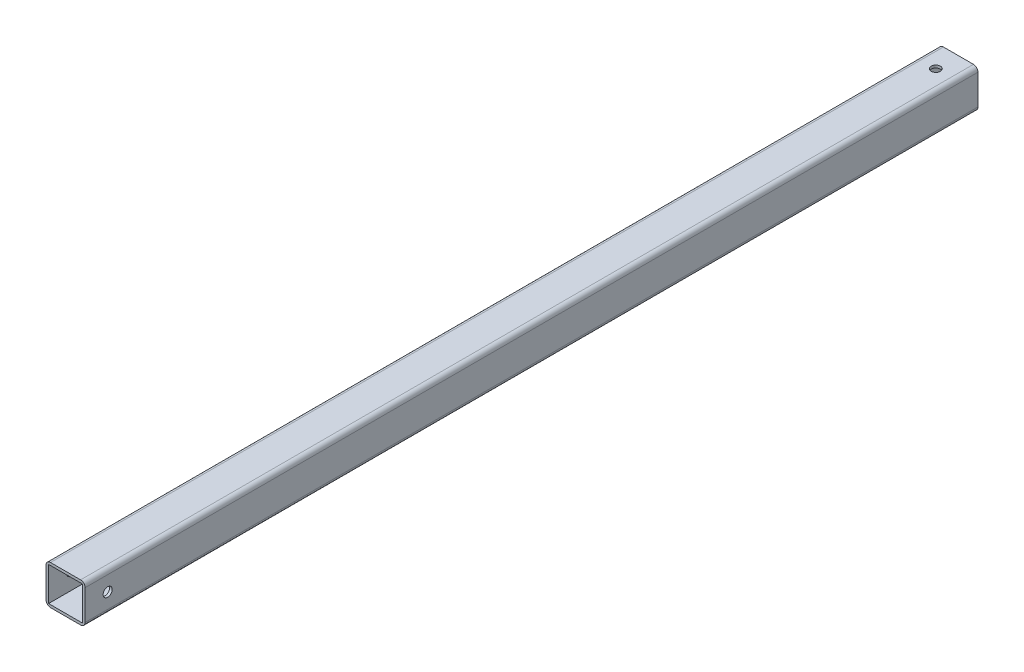
from build123d import *

# Parameters (mm, degrees)
SKETCH4_W                  = 21.971
SKETCH4_H                  = 21.971
SKETCH4_W_2                = 19.05
SKETCH4_H_2                = 19.05
BOSS_EXTRUDE2_DEPTH        = 501.65
FILLET1_R                  = 2.54
F_10_CLEARANCE_HOLE1_D     = 5.1054
F_10_CLEARANCE_HOLE1_DEPTH = 16.51
F_10_CLEARANCE_HOLE1_TIP   = 1.533816902
F_10_CLEARANCE_HOLE2_D     = 5.1054


with BuildPart() as part:
    # Sketch4 → Boss-Extrude2 (new body)
    with BuildSketch(Plane.XY):
        Rectangle(SKETCH4_W, SKETCH4_H)
        Rectangle(SKETCH4_W_2, SKETCH4_H_2, mode=Mode.SUBTRACT)
    extrude(amount=BOSS_EXTRUDE2_DEPTH)

    # Fillet1
    fillet1_edges = [part.edges().sort_by_distance(p)[0] for p in [
        (-10.9855, 10.9855, 250.825),
        (10.9855, 10.9855, 250.825),
        (10.9855, -10.9855, 250.825),
        (-10.9855, -10.9855, 250.825),
    ]]
    fillet(fillet1_edges, radius=FILLET1_R)

    # #10 Clearance Hole1
    with Locations(Plane(origin=(0, 10.9855, 0), x_dir=(1, 0, 0), z_dir=(0, 1, 0))):
        with Locations((0, -12.7)):
            Hole(F_10_CLEARANCE_HOLE1_D / 2, depth=F_10_CLEARANCE_HOLE1_DEPTH)
            with Locations((0, 0, -(F_10_CLEARANCE_HOLE1_DEPTH + F_10_CLEARANCE_HOLE1_TIP / 2))):  # 118° drill point
                Cone(0, F_10_CLEARANCE_HOLE1_D / 2, F_10_CLEARANCE_HOLE1_TIP, mode=Mode.SUBTRACT)

    # #10 Clearance Hole2 (through all)
    with Locations(Plane(origin=(10.9855, 0, 0), x_dir=(0, 0, -1), z_dir=(1, 0, 0))):
        with Locations((-488.95, 0)):
            Hole(F_10_CLEARANCE_HOLE2_D / 2)


solid = part.part
